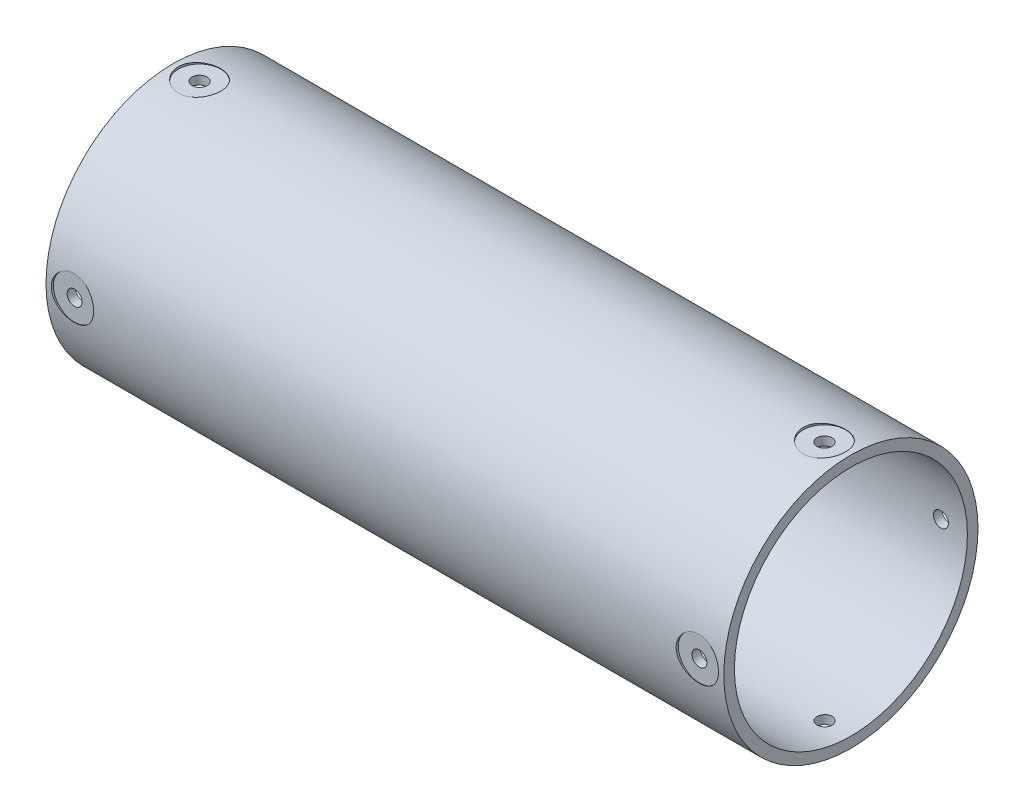
from build123d import *

# Parameters (mm, degrees)
SKETCH5_R               = 38.1
SKETCH5_R_2             = 34.925
BOSS_EXTRUDE3_DEPTH     = 101.6
CLEARANCE_HOLE0_REACH   = 215.039
CLEARANCE_HOLE0_BORE_R  = 2.2479
SKETCH10_R              = 6.35
CUT_EXTRUDE2_DEPTH      = 0.635
CIRPATTERN1_COUNT       = 4
MIRROR1_COPY_1_REACH    = 215.039
MIRROR1_COPY_1_SKETCH_R = 2.2479
MIRROR1_COPY_2_REACH    = 215.039
MIRROR1_COPY_2_SKETCH_R = 2.2479
MIRROR1_COPY_3_REACH    = 215.039
MIRROR1_COPY_3_SKETCH_R = 2.2479
MIRROR1_COPY_4_SKETCH_R = 6.35
MIRROR1_COPY_4_DEPTH    = 0.635
MIRROR1_COPY_5_SKETCH_R = 6.35
MIRROR1_COPY_5_DEPTH    = 0.635
MIRROR1_COPY_6_SKETCH_R = 6.35
MIRROR1_COPY_6_DEPTH    = 0.635


with BuildPart() as part:
    # Sketch5 → Boss-Extrude3 (new, symmetric)
    with BuildSketch(Plane(origin=(0, 0, 0), x_dir=(0, 0, -1), z_dir=(1, 0, 0))):
        Circle(SKETCH5_R)
        Circle(SKETCH5_R_2, mode=Mode.SUBTRACT)
    extrude(amount=BOSS_EXTRUDE3_DEPTH, both=True)

    # Clearance Hole0 bore (on position points) → Clearance Hole0 (cut, up to next)
    with BuildSketch(Plane(origin=(93.6625, 0, 38.1), x_dir=(1, 0, 0), z_dir=(0, 0, 1)), mode=Mode.PRIVATE) as clearance_hole0_sk1:
        Circle(CLEARANCE_HOLE0_BORE_R)
    clearance_hole0_tool1 = extrude(clearance_hole0_sk1.sketch, amount=-CLEARANCE_HOLE0_REACH, mode=Mode.PRIVATE) & part.part
    clearance_hole0 = clearance_hole0_tool1.solids().sort_by_distance((93.6625, 0, 38.1))[0]
    add(clearance_hole0, mode=Mode.SUBTRACT)

    # Sketch10 → Cut-Extrude2 (cut)
    with BuildSketch(Plane.XY.offset(38.1)):
        with Locations((93.6625, 0)):
            Circle(SKETCH10_R)
    cut_extrude2 = extrude(amount=-CUT_EXTRUDE2_DEPTH, mode=Mode.SUBTRACT)

    # CirPattern1: Clearance Hole0, Cut-Extrude2 ×4 about axis
    cirpattern1_axis = Axis((0, 0, 0), (1, 0, 0))
    add([clearance_hole0.rotate(cirpattern1_axis, i * 360 / CIRPATTERN1_COUNT) for i in range(1, CIRPATTERN1_COUNT)], mode=Mode.SUBTRACT)
    add([cut_extrude2.rotate(cirpattern1_axis, i * 360 / CIRPATTERN1_COUNT) for i in range(1, CIRPATTERN1_COUNT)], mode=Mode.SUBTRACT)

    # Mirror1: Clearance Hole0, Cut-Extrude2 across plane
    add(clearance_hole0.mirror(Plane(origin=(0, 0, 0), x_dir=(0, 0, 1), z_dir=(1, 0, 0))), mode=Mode.SUBTRACT)
    add(cut_extrude2.mirror(Plane(origin=(0, 0, 0), x_dir=(0, 0, 1), z_dir=(1, 0, 0))), mode=Mode.SUBTRACT)

    # Mirror1 copy 1 sketch → Mirror1 copy 1 (cut, up to next)
    with BuildSketch(Plane(origin=(-93.6625, -38.1, 0), x_dir=(-1, 0, 0), z_dir=(0, -1, 0)), mode=Mode.PRIVATE) as mirror1_copy_1_sk1:
        Circle(MIRROR1_COPY_1_SKETCH_R)
    mirror1_copy_1_tool1 = extrude(mirror1_copy_1_sk1.sketch, amount=-MIRROR1_COPY_1_REACH, mode=Mode.PRIVATE) & part.part
    add(mirror1_copy_1_tool1.solids().sort_by_distance((-93.6625, -38.1, 0))[0], mode=Mode.SUBTRACT)

    # Mirror1 copy 2 sketch → Mirror1 copy 2 (cut, up to next)
    with BuildSketch(Plane(origin=(-93.6625, 0, -38.1), x_dir=(-1, 0, 0), z_dir=(0, 0, -1)), mode=Mode.PRIVATE) as mirror1_copy_2_sk1:
        Circle(MIRROR1_COPY_2_SKETCH_R)
    mirror1_copy_2_tool1 = extrude(mirror1_copy_2_sk1.sketch, amount=-MIRROR1_COPY_2_REACH, mode=Mode.PRIVATE) & part.part
    add(mirror1_copy_2_tool1.solids().sort_by_distance((-93.6625, 0, -38.1))[0], mode=Mode.SUBTRACT)

    # Mirror1 copy 3 sketch → Mirror1 copy 3 (cut, up to next)
    with BuildSketch(Plane(origin=(-93.6625, 38.1, 0), x_dir=(-1, 0, 0), z_dir=(0, 1, 0)), mode=Mode.PRIVATE) as mirror1_copy_3_sk1:
        Circle(MIRROR1_COPY_3_SKETCH_R)
    mirror1_copy_3_tool1 = extrude(mirror1_copy_3_sk1.sketch, amount=-MIRROR1_COPY_3_REACH, mode=Mode.PRIVATE) & part.part
    add(mirror1_copy_3_tool1.solids().sort_by_distance((-93.6625, 38.1, 0))[0], mode=Mode.SUBTRACT)

    # Mirror1 copy 4 sketch → Mirror1 copy 4 (cut)
    with BuildSketch(Plane(origin=(0, -38.1, 0), x_dir=(-1, 0, 0), z_dir=(0, -1, 0))):
        with Locations((93.6625, 0)):
            Circle(MIRROR1_COPY_4_SKETCH_R)
    extrude(amount=-MIRROR1_COPY_4_DEPTH, mode=Mode.SUBTRACT)

    # Mirror1 copy 5 sketch → Mirror1 copy 5 (cut)
    with BuildSketch(Plane(origin=(0, 0, -38.1), x_dir=(-1, 0, 0), z_dir=(0, 0, -1))):
        with Locations((93.6625, 0)):
            Circle(MIRROR1_COPY_5_SKETCH_R)
    extrude(amount=-MIRROR1_COPY_5_DEPTH, mode=Mode.SUBTRACT)

    # Mirror1 copy 6 sketch → Mirror1 copy 6 (cut)
    with BuildSketch(Plane(origin=(0, 38.1, 0), x_dir=(-1, 0, 0), z_dir=(0, 1, 0))):
        with Locations((93.6625, 0)):
            Circle(MIRROR1_COPY_6_SKETCH_R)
    extrude(amount=-MIRROR1_COPY_6_DEPTH, mode=Mode.SUBTRACT)


solid = part.part
